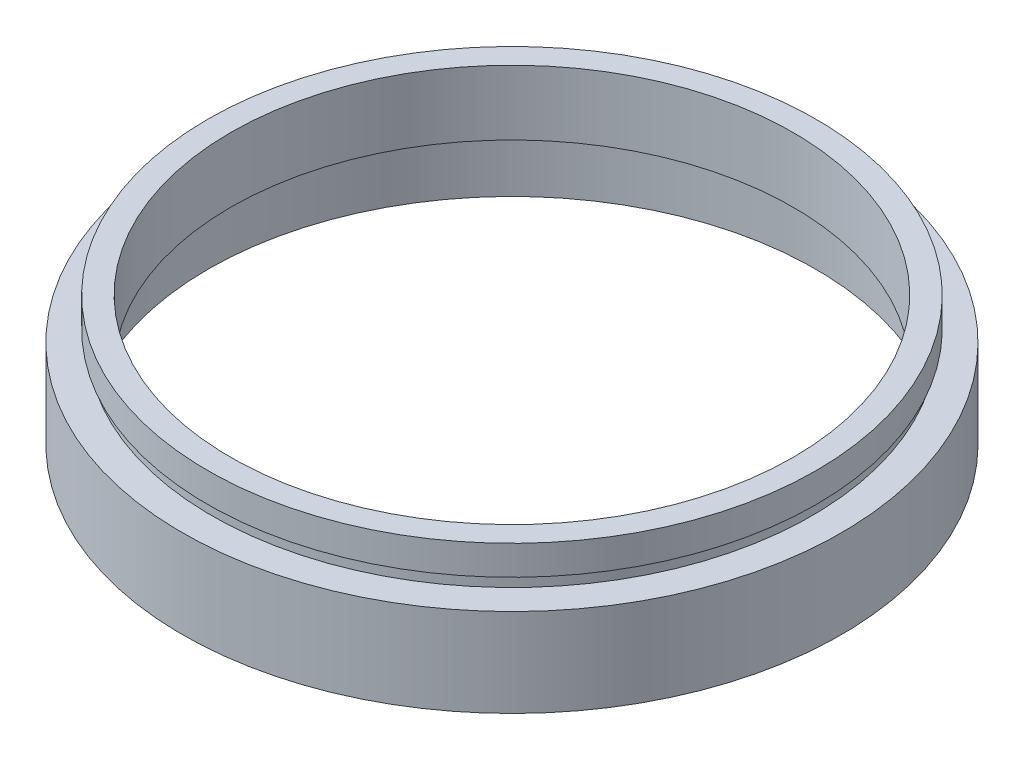
from build123d import *


with BuildPart() as part:
    # 草图1 → 旋转1 (revolve)
    with BuildSketch(Plane.XY, mode=Mode.PRIVATE) as revolve_1_sk:
        Polygon((25.8, 0), (25.8, 4.5), (26.1, 4.5), (26.1, 5.5), (23.9, 5.5), (23.9, 11), (25.85, 11), (25.85, 8.5), (25.5, 8.5), (25.5, 7.5), (28, 7.5), (28, 0), align=None)
    revolve(revolve_1_sk.sketch.rotate(Axis((0, 16.886018237, 0), (0, -1, 0)), 180), axis=Axis((0, 16.886018237, 0), (0, -1, 0)))  # turned: the seam where the file's is


solid = part.part
